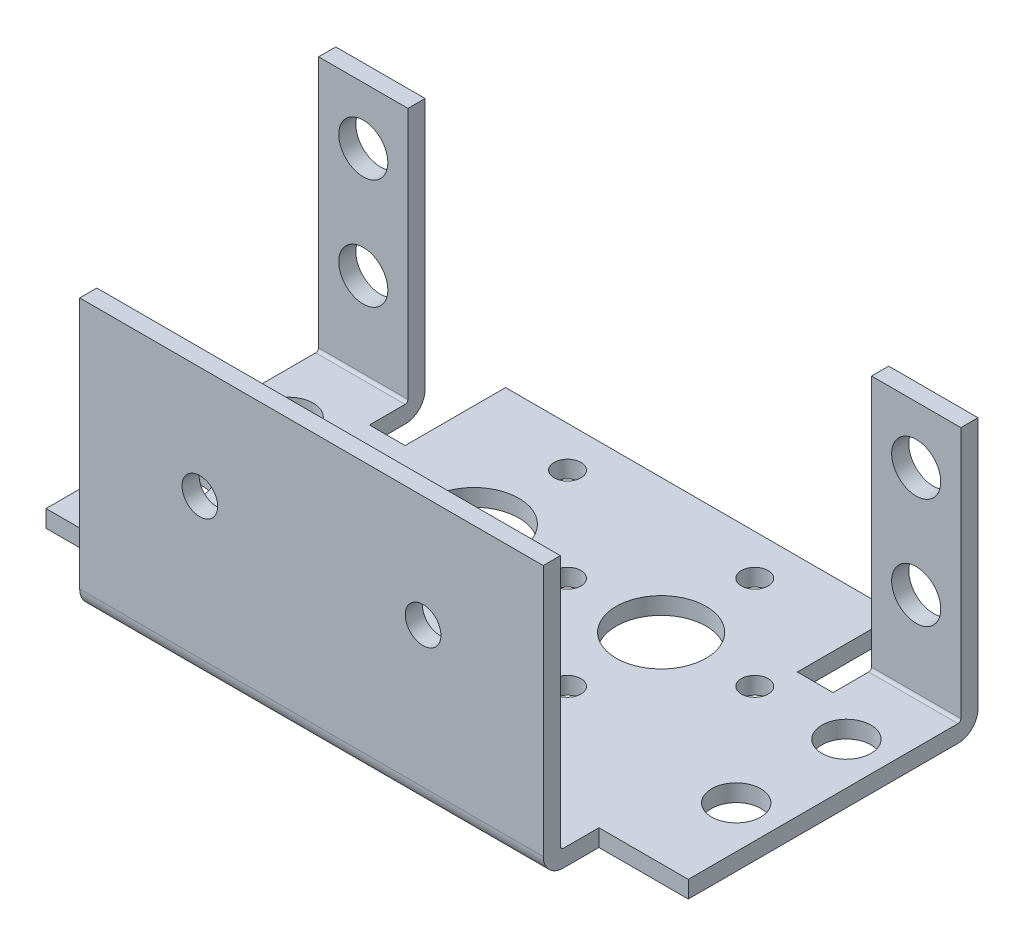
from build123d import *

# Parameters (mm, degrees)
SKETCH1_R      = 2.1844
SKETCH1_R_2    = 1.1938
SKETCH1_R_3    = 4.0005
EXTRUDE1_DEPTH = 1.524
EXTRUDE3_START = -13.3731
SKETCH3_W      = 7.9502
SKETCH3_H      = 24.2062
SKETCH3_R      = 2.1844
EXTRUDE3_DEPTH = 1.524
EXTRUDE4_START = 15.8369
SKETCH3_3_W    = 41.2496
SKETCH3_3_H    = 24.2062
SKETCH3_3_R    = 1.5875
EXTRUDE4_DEPTH = 1.524
FILLET4_R      = 1.778
FILLET5_R      = 0.254


with BuildPart() as part:
    # Sketch1 → Extrude1 (new body)
    with BuildSketch(Plane(origin=(0, 0, 0), x_dir=(1, 0, 0), z_dir=(0, 1, 0))):
        Polygon((28.575, -12.4079), (28.575, 13.3731), (20.6248, 13.3731), (20.6248, 8.4201), (17.4498, 8.4201), (17.4498, 17.3609), (-17.4498, 17.3609), (-17.4498, 8.4201), (-20.6248, 8.4201), (-20.6248, 13.3731), (-28.575, 13.3731), (-28.575, -12.4079), (-20.6248, -12.4079), (-20.6248, -17.3609), (20.6248, -17.3609), (20.6248, -12.4079), align=None)
        with Locations((-24.8158, -4.3815)):
            Circle(SKETCH1_R, mode=Mode.SUBTRACT)
        with Locations((-8.3312, -2.9083)):
            Circle(SKETCH1_R_2, mode=Mode.SUBTRACT)
        with Locations((8.3312, -2.9083)):
            Circle(SKETCH1_R_2, mode=Mode.SUBTRACT)
        with Locations((24.8158, -4.3815)):
            Circle(SKETCH1_R, mode=Mode.SUBTRACT)
        with Locations((8.3312, 13.7541)):
            Circle(SKETCH1_R_2, mode=Mode.SUBTRACT)
        with Locations((-24.8158, 5.4229)):
            Circle(SKETCH1_R, mode=Mode.SUBTRACT)
        with Locations((-16.6624, 5.4229)):
            Circle(SKETCH1_R_2, mode=Mode.SUBTRACT)
        with Locations((-8.3312, 5.4229)):
            Circle(SKETCH1_R_3, mode=Mode.SUBTRACT)
        with Locations((-8.3312, 13.7541)):
            Circle(SKETCH1_R_2, mode=Mode.SUBTRACT)
        with Locations((0, 5.4229)):
            Circle(SKETCH1_R_2, mode=Mode.SUBTRACT)
        with Locations((8.3312, 5.4229)):
            Circle(SKETCH1_R_3, mode=Mode.SUBTRACT)
        with Locations((16.6624, 5.4229)):
            Circle(SKETCH1_R_2, mode=Mode.SUBTRACT)
        with Locations((24.8158, 5.4229)):
            Circle(SKETCH1_R, mode=Mode.SUBTRACT)
    extrude(amount=EXTRUDE1_DEPTH)

    # Sketch3 → Extrude3 (add)
    with BuildSketch(Plane.XY.offset(EXTRUDE3_START)):
        with Locations((-24.5999, 12.1031)):
            Rectangle(SKETCH3_W, SKETCH3_H)
        with Locations((-24.5999, 19.1262)):
            Circle(SKETCH3_R, mode=Mode.SUBTRACT)
        with Locations((-24.5999, 9.3218)):
            Circle(SKETCH3_R, mode=Mode.SUBTRACT)
        with Locations((24.5999, 12.1031)):
            Rectangle(SKETCH3_W, SKETCH3_H)
        with Locations((24.5999, 9.3218)):
            Circle(SKETCH3_R, mode=Mode.SUBTRACT)
        with Locations((24.5999, 19.1262)):
            Circle(SKETCH3_R, mode=Mode.SUBTRACT)
    extrude(amount=EXTRUDE3_DEPTH)

    # Sketch3_3 → Extrude4 (add)
    with BuildSketch(Plane.XY.offset(EXTRUDE4_START)):
        with Locations((0, 12.1031)):
            Rectangle(SKETCH3_3_W, SKETCH3_3_H)
        with Locations((-9.9314, 14.2748)):
            Circle(SKETCH3_3_R, mode=Mode.SUBTRACT)
        with Locations((9.9314, 14.2748)):
            Circle(SKETCH3_3_R, mode=Mode.SUBTRACT)
    extrude(amount=EXTRUDE4_DEPTH)

    # Fillet4
    fillet4_edges = [part.edges().sort_by_distance(p)[0] for p in [
        (0, 0, 17.3609),
        (-24.5999, 0, -13.3731),
        (24.5999, 0, -13.3731),
    ]]
    fillet(fillet4_edges, radius=FILLET4_R)

    # Fillet5
    fillet5_edges = [part.edges().sort_by_distance(p)[0] for p in [
        (24.5999, 1.524, -11.8491),
        (0, 1.524, 15.8369),
        (-24.5999, 1.524, -11.8491),
    ]]
    fillet(fillet5_edges, radius=FILLET5_R)


solid = part.part
